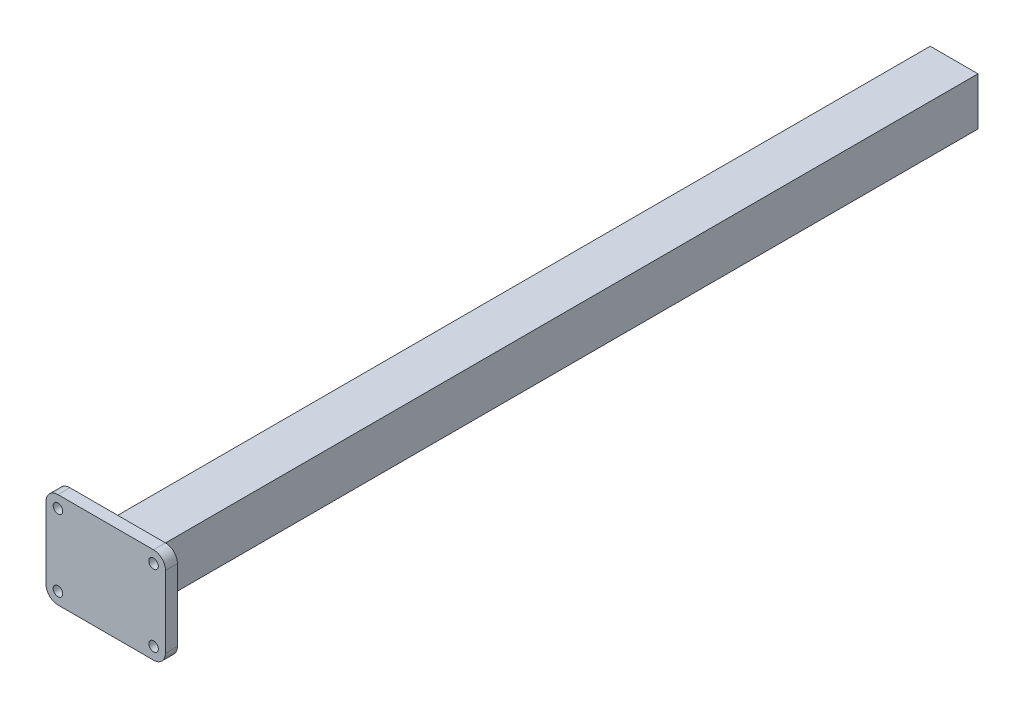
from build123d import *

# Parameters (mm, degrees)
ESQUISSE1_W             = 40
ESQUISSE1_H             = 40
ESQUISSE1_W_2           = 37
ESQUISSE1_H_2           = 37
BOSS_EXTRU_1_DEPTH      = 700
BOSS_EXTRU_2_DEPTH      = 10
ESQUISSE3_R             = 4
ENL_V_MAT_EXTRU_1_DEPTH = 10


with BuildPart() as part:
    # Esquisse1 → Boss.-Extru.1 (new body)
    with BuildSketch(Plane.XY):
        Rectangle(ESQUISSE1_W, ESQUISSE1_H)
        Rectangle(ESQUISSE1_W_2, ESQUISSE1_H_2, mode=Mode.SUBTRACT)
    extrude(amount=BOSS_EXTRU_1_DEPTH)

    # Esquisse2 → Boss.-Extru.2 (add)
    with BuildSketch(Plane.XY.offset(700)):
        with BuildLine():
            Line((-40, -40), (40, -40))
            ThreePointArc((40, -40), (47.071067812, -37.071067812), (50, -30))
            Line((50, -30), (50, 30))
            ThreePointArc((50, 30), (47.071067812, 37.071067812), (40, 40))
            Line((40, 40), (-40, 40))
            ThreePointArc((-40, 40), (-47.071067812, 37.071067812), (-50, 30))
            Line((-50, 30), (-50, -30))
            ThreePointArc((-50, -30), (-47.071067812, -37.071067812), (-40, -40))
        make_face()
    extrude(amount=BOSS_EXTRU_2_DEPTH)

    # Esquisse3 → Enlèv. mat.-Extru.1 (cut)
    with BuildSketch(Plane(origin=(0, 0, 700), x_dir=(-1, 0, 0), z_dir=(0, 0, -1))):
        with Locations((40, 30)):
            Circle(ESQUISSE3_R)
        with Locations((-40, 30)):
            Circle(ESQUISSE3_R)
        with Locations((-40, -30)):
            Circle(ESQUISSE3_R)
        with Locations((40, -30)):
            Circle(ESQUISSE3_R)
    extrude(amount=-ENL_V_MAT_EXTRU_1_DEPTH, mode=Mode.SUBTRACT)


solid = part.part
